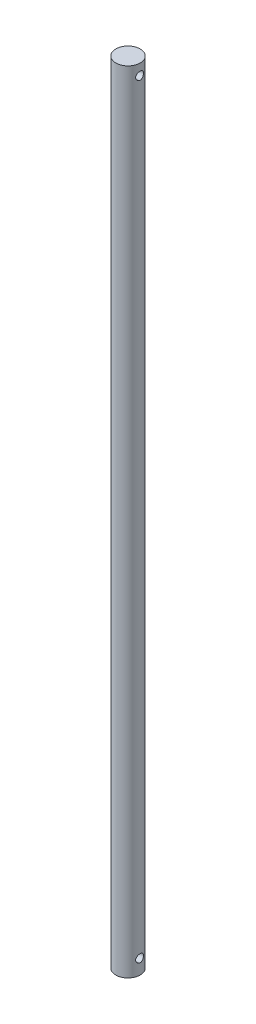
from build123d import *

# Parameters (mm, degrees)
SKETCH1_W               = 10
SKETCH1_H               = 647.7
SKETCH2_R               = 3.2
CUT_EXTRUDE1_DEPTH      = 11
CUT_EXTRUDE1_DEPTH_BACK = 11


with BuildPart() as part:
    # Sketch1 → Revolve2 (revolve)
    with BuildSketch(Plane(origin=(0, 0, 0), x_dir=(0, 0, -1), z_dir=(1, 0, 0))):
        with Locations((-5, 323.85)):
            Rectangle(SKETCH1_W, SKETCH1_H)
    revolve(axis=Axis((0, 0, 0), (0, 1, 0)))

    # Sketch2 → Cut-Extrude1 (cut, two sides)
    with BuildSketch(Plane(origin=(0, 0, 0), x_dir=(0, 0, -1), z_dir=(1, 0, 0))) as cut_extrude1_sk:
        with Locations((0, 638.7)):
            Circle(SKETCH2_R)
        with Locations((0, 12)):
            Circle(SKETCH2_R)
    extrude(amount=CUT_EXTRUDE1_DEPTH, mode=Mode.SUBTRACT)
    extrude(cut_extrude1_sk.sketch, amount=-CUT_EXTRUDE1_DEPTH_BACK, mode=Mode.SUBTRACT)


solid = part.part
